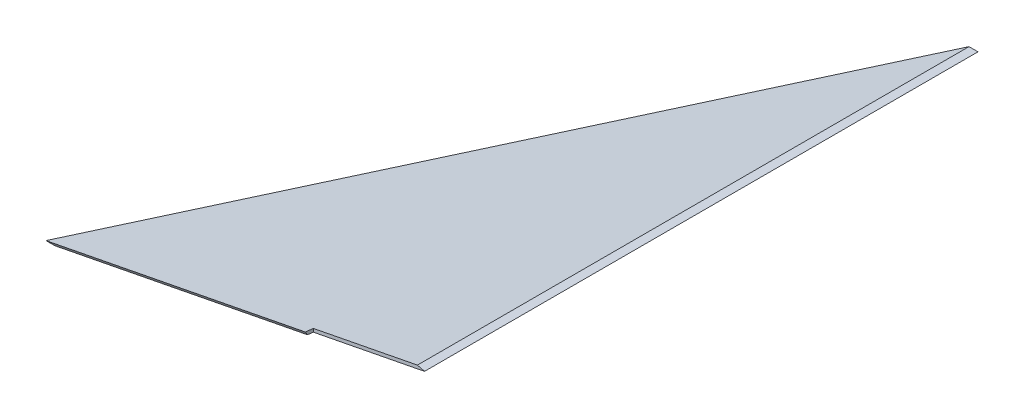
from build123d import *

# Parameters (mm, degrees)
BOSS_EXTRUDE1_DEPTH     = 304.8
CUT_EXTRUDE1_DEPTH      = 198.18
CUT_EXTRUDE1_DEPTH_BACK = 1
CUT_EXTRUDE2_DEPTH      = 60.305329017


with BuildPart() as part:
    # Sketch1 → Boss-Extrude1 (new body)
    with BuildSketch(Plane(origin=(0, 0, 0), x_dir=(0, 0, -1), z_dir=(1, 0, 0))):
        Polygon((0, 0), (-197.18, 0), (-162.940052328, -59.305329017), align=None)
    extrude(amount=BOSS_EXTRUDE1_DEPTH)

    # Sketch2 → Cut-Extrude1 (cut, two sides)
    with BuildSketch(Plane.XY) as cut_extrude1_sk:
        Polygon((138.684947672, -59.305329017), (301.625, 0), (0, 0), (0, -59.305329017), align=None)
        Polygon((304.8, 0), (141.859947672, -59.305329017), (304.8, -59.305329017), align=None)
    extrude(amount=CUT_EXTRUDE1_DEPTH, mode=Mode.SUBTRACT)
    extrude(cut_extrude1_sk.sketch, amount=-CUT_EXTRUDE1_DEPTH_BACK, mode=Mode.SUBTRACT)

    # Sketch3 → Cut-Extrude2 (cut, through all)
    with BuildSketch(Plane(origin=(0, 0, 0), x_dir=(1, 0, 0), z_dir=(0, 1, 0))):
        Polygon((254.596089188, -187.297424032), (301.625, -197.18), (301.625, -194.746742189), (255.085785802, -184.967070242), align=None)
        Polygon((301.625, -194.746742189), (301.625, -197.18), (304.8, -197.18), (304.8, -195.413931332), align=None)
    extrude(amount=-CUT_EXTRUDE2_DEPTH, mode=Mode.SUBTRACT)


solid = part.part
